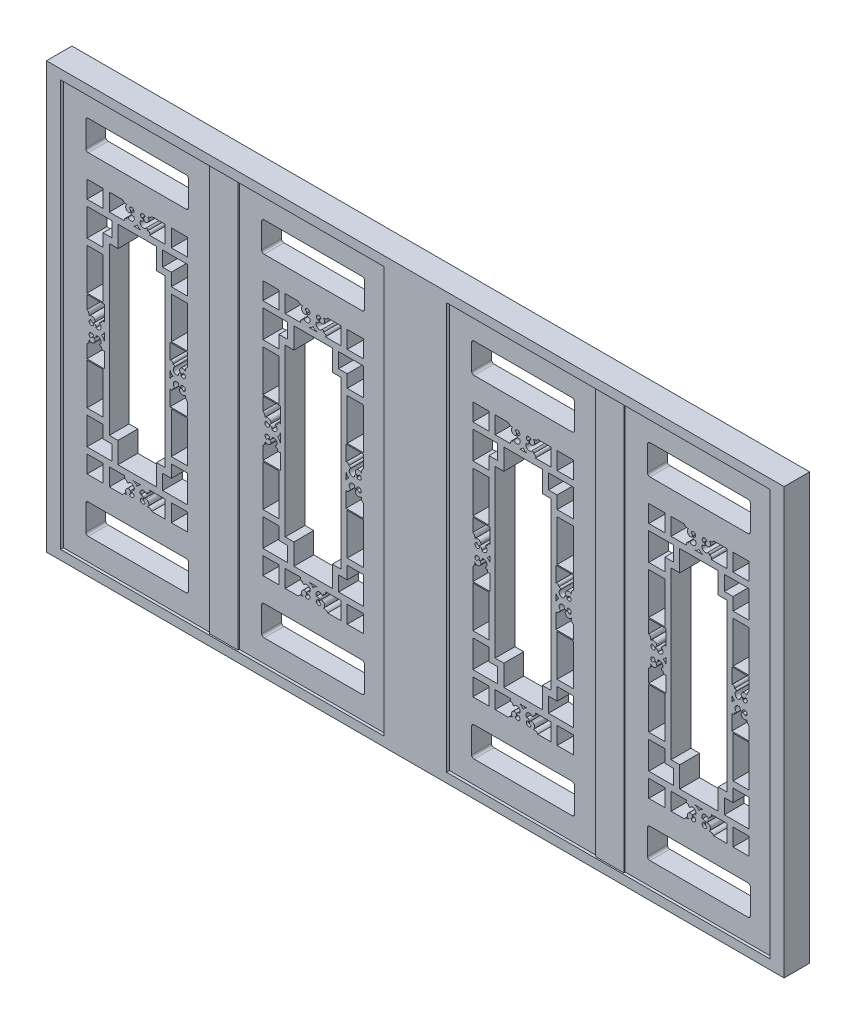
from build123d import *

# Parameters (mm, degrees)
SKETCH1_W              = 595
SKETCH1_H              = 1640
BOSS_EXTRUDE1_DEPTH    = 180
SKETCH_6_W             = 595
SKETCH_6_H             = 1640
CUT_EXTRUDE_2_DEPTH    = 100
CUT_EXTRUDE_3_DEPTH    = 100
SKETCH2_W              = 65
SKETCH2_H              = 70
SKETCH2_H_2            = 167
CUT_EXTRUDE_5_DEPTH    = 81
CUT_EXTRUDE_8_DEPTH    = 81
SCALE_1_SCALE          = 0.87394958
PATTERN_LINEAR_7_COUNT = 2
PATTERN_LINEAR_7_PITCH = 620
PATTERN_LINEAR_8_COUNT = 2
PATTERN_LINEAR_8_PITCH = 1360
SKETCH_10_W            = 2600
SKETCH_10_H            = 1500
SKETCH_10_W_2          = 1140
SKETCH_10_H_2          = 1433.277310924
EXTRUDE_3_DEPTH        = 10
EXTRUDE_3_DEPTH_BACK   = 79.92
SKETCH_11_W            = 100
SKETCH_11_H            = 1433.277310924
EXTRUDE_4_DEPTH        = 5
EXTRUDE_4_DEPTH_BACK   = 74.92


with BuildPart() as part:
    # Sketch1 → Boss-Extrude1 (new body)
    with BuildSketch(Plane.XY):
        with Locations((297.5, 820)):
            Rectangle(SKETCH1_W, SKETCH1_H)
    extrude(amount=BOSS_EXTRUDE1_DEPTH)

    # 草图6 → 切除-拉伸2 (cut)
    with BuildSketch(Plane.XY.offset(180)):
        with Locations((297.5, 820)):
            Rectangle(SKETCH_6_W, SKETCH_6_H)
    extrude(amount=-CUT_EXTRUDE_2_DEPTH, mode=Mode.SUBTRACT)

    # 草图1 → 切除-拉伸3 (cut)
    with BuildSketch(Plane(origin=(0, 0, 0), x_dir=(-1, 0, 0), z_dir=(0, 0, -1))):
        with BuildLine():
            ThreePointArc((-339.478697135, 363.442307012), (-347.464207716, 366.462464977), (-347.449072001, 375))
            Line((-347.449072001, 375), (-410, 375))
            Line((-410, 375), (-410, 305))
            Line((-410, 305), (-356.673331708, 305))
            ThreePointArc((-356.673331708, 305), (-348.94904931, 312.012889726), (-338.529552639, 312.541330816))
            ThreePointArc((-338.529552639, 312.541330816), (-344.046220029, 325.924483031), (-334.768909443, 337.036363636))
            ThreePointArc((-334.768909443, 337.036363636), (-323.949287324, 331.726907665), (-329.315168468, 320.935157804))
            ThreePointArc((-329.315168468, 320.935157804), (-314.478603669, 315.069270244), (-315.214046212, 331.006378394))
            ThreePointArc((-315.214046212, 331.006378394), (-318.365986632, 330.765395418), (-320.358708006, 328.311447022))
            ThreePointArc((-320.358708006, 328.311447022), (-320.882047686, 338.069212343), (-311.577227356, 341.053870966))
            ThreePointArc((-311.577227356, 341.053870966), (-311.192434776, 341.798442865), (-310.72696898, 342.495432272))
            ThreePointArc((-310.72696898, 342.495432272), (-316.343126273, 360.498534643), (-334.477239272, 355.321000146))
            ThreePointArc((-334.477239272, 355.321000146), (-338.751843962, 358.289222889), (-339.478697135, 363.442307012))
        make_face()
        with BuildLine():
            Line((-185, 375), (-247.550927999, 375))
            ThreePointArc((-247.550927999, 375), (-247.535792284, 366.462464977), (-255.521302865, 363.442307012))
            ThreePointArc((-255.521302865, 363.442307012), (-256.248156038, 358.289222889), (-260.522760728, 355.321000146))
            ThreePointArc((-260.522760728, 355.321000146), (-278.656873727, 360.498534643), (-284.27303102, 342.495432272))
            ThreePointArc((-284.27303102, 342.495432272), (-283.807565224, 341.798442865), (-283.422772644, 341.053870966))
            ThreePointArc((-283.422772644, 341.053870966), (-274.117952314, 338.069212343), (-274.641291994, 328.311447022))
            ThreePointArc((-274.641291994, 328.311447022), (-276.634013368, 330.765395418), (-279.785953788, 331.006378394))
            ThreePointArc((-279.785953788, 331.006378394), (-280.521396331, 315.069270244), (-265.684831532, 320.935157804))
            ThreePointArc((-265.684831532, 320.935157804), (-271.050712676, 331.726907665), (-260.231090557, 337.036363636))
            ThreePointArc((-260.231090557, 337.036363636), (-250.953779971, 325.924483031), (-256.470447361, 312.541330816))
            ThreePointArc((-256.470447361, 312.541330816), (-246.05095069, 312.012889726), (-238.326668292, 305))
            Line((-238.326668292, 305), (-185, 305))
            Line((-185, 305), (-185, 375))
        make_face()
        with BuildLine():
            ThreePointArc((-279.5, 375), (-290.126074317, 371.412833197), (-297.5, 362.9626))
            ThreePointArc((-297.5, 362.9626), (-304.873925683, 371.412833197), (-315.5, 375))
            Line((-315.5, 375), (-279.5, 375))
        make_face()
    cut_extrude_3 = extrude(amount=-CUT_EXTRUDE_3_DEPTH, mode=Mode.SUBTRACT)

    # Sketch2 → 切除-拉伸5 (cut, through all)
    with BuildSketch(Plane(origin=(0, 0, 0), x_dir=(-1, 0, 0), z_dir=(0, 0, -1))):
        with BuildLine():
            Line((-100, 90), (-495, 90))
            ThreePointArc((-495, 90), (-502.071067812, 92.928932188), (-505, 100))
            Line((-505, 100), (-505, 200))
            ThreePointArc((-505, 200), (-502.071067812, 207.071067812), (-495, 210))
            Line((-495, 210), (-100, 210))
            ThreePointArc((-100, 210), (-92.928932188, 207.071067812), (-90, 200))
            Line((-90, 200), (-90, 100))
            ThreePointArc((-90, 100), (-92.928932188, 92.928932188), (-100, 90))
        make_face()
        with Locations((-467.5, 340)):
            Rectangle(SKETCH2_W, SKETCH2_H)
        with Locations((-127.5, 340)):
            Rectangle(SKETCH2_W, SKETCH2_H)
        Polygon((-435, 511), (-500, 511), (-500, 400), (-400, 400), (-400, 460), (-435, 460), align=None)
        Polygon((-195, 460), (-195, 400), (-95, 400), (-95, 511), (-160, 511), (-160, 460), align=None)
        with Locations((-467.5, 619.5)):
            Rectangle(SKETCH2_W, SKETCH2_H_2)
        with Locations((-127.5, 619.5)):
            Rectangle(SKETCH2_W, SKETCH2_H_2)
        Polygon((-220, 1240), (-375, 1240), (-375, 1155), (-410, 1155), (-410, 485), (-375, 485), (-375, 400), (-220, 400), (-220, 485), (-185, 485), (-185, 1155), (-220, 1155), align=None)
        with Locations((-467.5, 1020.5)):
            Rectangle(SKETCH2_W, SKETCH2_H_2)
        with Locations((-127.5, 1020.5)):
            Rectangle(SKETCH2_W, SKETCH2_H_2)
        Polygon((-95, 1240), (-195, 1240), (-195, 1180), (-160, 1180), (-160, 1129), (-95, 1129), align=None)
        with Locations((-127.5, 1300)):
            Rectangle(SKETCH2_W, SKETCH2_H)
        with Locations((-467.5, 1300)):
            Rectangle(SKETCH2_W, SKETCH2_H)
        Polygon((-400, 1240), (-500, 1240), (-500, 1129), (-435, 1129), (-435, 1180), (-400, 1180), align=None)
        with BuildLine():
            Line((-495, 1430), (-100, 1430))
            ThreePointArc((-100, 1430), (-92.928932188, 1432.928932188), (-90, 1440))
            Line((-90, 1440), (-90, 1540))
            ThreePointArc((-90, 1540), (-92.928932188, 1547.071067812), (-100, 1550))
            Line((-100, 1550), (-495, 1550))
            ThreePointArc((-495, 1550), (-502.071067812, 1547.071067812), (-505, 1540))
            Line((-505, 1540), (-505, 1440))
            ThreePointArc((-505, 1440), (-502.071067812, 1432.928932188), (-495, 1430))
        make_face()
    extrude(amount=-CUT_EXTRUDE_5_DEPTH, mode=Mode.SUBTRACT)

    # 镜向1: 切除-拉伸3 across plane
    add(cut_extrude_3.mirror(Plane.ZX.offset(820)), mode=Mode.SUBTRACT)

    # 草图1<5> → 切除-拉伸8 (cut, through all)
    with BuildSketch(Plane(origin=(0, 0, 0), x_dir=(-1, 0, 0), z_dir=(0, 0, -1))):
        with BuildLine():
            Line((-430, 869.949072001), (-430, 932.5))
            Line((-430, 932.5), (-500, 932.5))
            Line((-500, 932.5), (-500, 879.173331708))
            ThreePointArc((-500, 879.173331708), (-492.987110274, 871.44904931), (-492.458669184, 861.029552639))
            ThreePointArc((-492.458669184, 861.029552639), (-479.075516969, 866.546220029), (-467.963636364, 857.268909443))
            ThreePointArc((-467.963636364, 857.268909443), (-473.273092335, 846.449287324), (-484.064842196, 851.815168468))
            ThreePointArc((-484.064842196, 851.815168468), (-489.930729756, 836.978603669), (-473.993621606, 837.714046212))
            ThreePointArc((-473.993621606, 837.714046212), (-474.234604582, 840.865986631), (-476.688552978, 842.858708006))
            ThreePointArc((-476.688552978, 842.858708006), (-466.930787657, 843.382047686), (-463.946129034, 834.077227356))
            ThreePointArc((-463.946129034, 834.077227356), (-463.201557135, 833.692434776), (-462.504567728, 833.22696898))
            ThreePointArc((-462.504567728, 833.22696898), (-444.501465357, 838.843126273), (-449.678999854, 856.977239272))
            ThreePointArc((-449.678999854, 856.977239272), (-446.710777111, 861.251843962), (-441.557692988, 861.978697135))
            ThreePointArc((-441.557692988, 861.978697135), (-438.537535023, 869.964207716), (-430, 869.949072001))
        make_face()
        with BuildLine():
            Line((-500, 760.826668292), (-500, 707.5))
            Line((-500, 707.5), (-430, 707.5))
            Line((-430, 707.5), (-430, 770.050927999))
            ThreePointArc((-430, 770.050927999), (-438.537535023, 770.035792284), (-441.557692988, 778.021302865))
            ThreePointArc((-441.557692988, 778.021302865), (-446.710777111, 778.748156038), (-449.678999854, 783.022760728))
            ThreePointArc((-449.678999854, 783.022760728), (-444.501465357, 801.156873727), (-462.504567728, 806.77303102))
            ThreePointArc((-462.504567728, 806.77303102), (-463.201557135, 806.307565224), (-463.946129034, 805.922772644))
            ThreePointArc((-463.946129034, 805.922772644), (-466.930787657, 796.617952314), (-476.688552978, 797.141291994))
            ThreePointArc((-476.688552978, 797.141291994), (-474.234604582, 799.134013368), (-473.993621606, 802.285953788))
            ThreePointArc((-473.993621606, 802.285953788), (-489.930729756, 803.021396331), (-484.064842196, 788.184831532))
            ThreePointArc((-484.064842196, 788.184831532), (-473.273092335, 793.550712676), (-467.963636364, 782.731090557))
            ThreePointArc((-467.963636364, 782.731090557), (-479.075516969, 773.453779971), (-492.458669184, 778.970447361))
            ThreePointArc((-492.458669184, 778.970447361), (-492.987110274, 768.55095069), (-500, 760.826668292))
        make_face()
        with BuildLine():
            ThreePointArc((-442.0374, 820), (-433.587166803, 827.373925683), (-430, 838))
            Line((-430, 838), (-430, 802))
            ThreePointArc((-430, 802), (-433.587166803, 812.626074317), (-442.0374, 820))
        make_face()
    cut_extrude_8 = extrude(amount=-CUT_EXTRUDE_8_DEPTH, mode=Mode.SUBTRACT)

    # 镜向3: 切除-拉伸8 across plane
    add(cut_extrude_8.mirror(Plane.ZY.offset(-297.5)), mode=Mode.SUBTRACT)


with BuildPart() as part_1:
    # 缩放比例1: scaled about (297.5, 820, 40)
    add(part.part.scale(SCALE_1_SCALE).moved(Location((37.5, 103.361344538, 5.042016807))))


with BuildPart() as pattern_linear_7_1:
    # 阵列(线性)7: pattern copy
    add(part_1.part.moved(Location(Vector(-1, 0, 0) * (1 * PATTERN_LINEAR_7_PITCH))))


with BuildPart() as pattern_linear_8_1:
    # 阵列(线性)8: pattern copy
    add(part_1.part.moved(Location(Vector(-1, 0, 0) * (1 * PATTERN_LINEAR_8_PITCH))))


with BuildPart() as pattern_linear_8_2:
    # 阵列(线性)8: pattern copy
    add(pattern_linear_7_1.part.moved(Location(Vector(-1, 0, 0) * (1 * PATTERN_LINEAR_8_PITCH))))


with BuildPart() as part_2:
    add(part_1.part)

    add(pattern_linear_7_1.part)  # 凸台-拉伸3 merges 阵列(线性)7_1

    add(pattern_linear_8_1.part)  # 凸台-拉伸3 merges 阵列(线性)8_1

    add(pattern_linear_8_2.part)  # 凸台-拉伸3 merges 阵列(线性)8_2
    # 草图10 → 凸台-拉伸3 (add, two sides)
    with BuildSketch(Plane.XY.offset(74.957983193)) as extrude_3_sk:
        with Locations((-692.5, 820.001344538)):
            Rectangle(SKETCH_10_W, SKETCH_10_H)
        with Locations((-1372.5, 820)):
            Rectangle(SKETCH_10_W_2, SKETCH_10_H_2, mode=Mode.SUBTRACT)
        with Locations((-12.5, 820)):
            Rectangle(SKETCH_10_W_2, SKETCH_10_H_2, mode=Mode.SUBTRACT)
    extrude(amount=EXTRUDE_3_DEPTH)
    extrude(extrude_3_sk.sketch, amount=-EXTRUDE_3_DEPTH_BACK)

    # 草图11 → 凸台-拉伸4 (add, two sides)
    with BuildSketch(Plane.XY.offset(74.957983193)) as extrude_4_sk:
        with Locations((-1372.5, 820)):
            Rectangle(SKETCH_11_W, SKETCH_11_H)
        with Locations((-12.5, 820)):
            Rectangle(SKETCH_11_W, SKETCH_11_H)
    extrude(amount=EXTRUDE_4_DEPTH)
    extrude(extrude_4_sk.sketch, amount=-EXTRUDE_4_DEPTH_BACK)


solid = part_2.part
